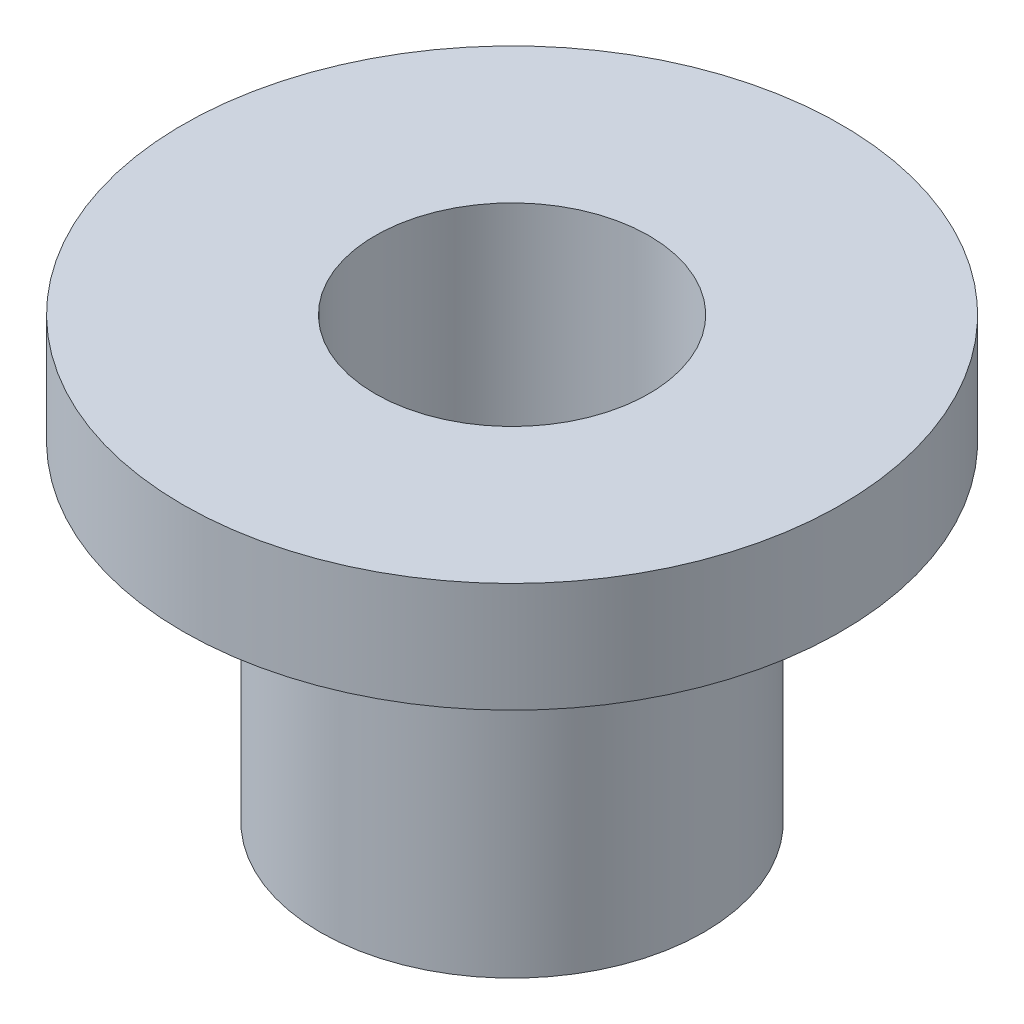
from build123d import *


with BuildPart() as part:
    # Sketch1 → Revolve1 (revolve)
    with BuildSketch(Plane.XY):
        Polygon((-9.525, 0), (-3.9624, 0), (-3.9624, -12.7), (-5.5499, -12.7), (-5.5499, -3.175), (-9.525, -3.175), align=None)
    revolve(axis=Axis((0, 0, 0), (0, -1, 0)))


solid = part.part
